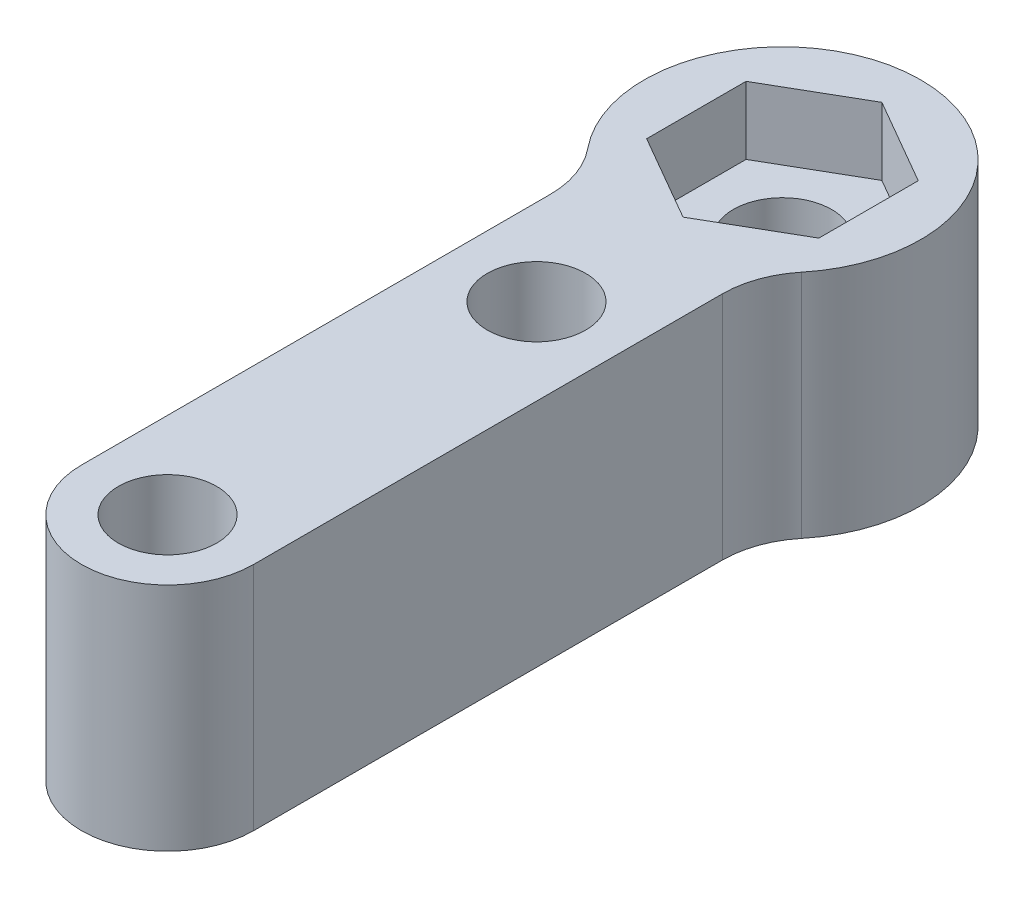
from build123d import *

# Parameters (mm, degrees)
SKETCH1_R           = 1.6
BOSS_EXTRUDE1_DEPTH = 7.5
CUT_EXTRUDE1_DEPTH  = 2.2
FILLET1_R           = 3


with BuildPart() as part:
    # Sketch1 → Boss-Extrude1 (new body)
    with BuildSketch(Plane(origin=(0, 0, 0), x_dir=(1, 0, 0), z_dir=(0, 1, 0))):
        with BuildLine():
            Line((-2.8, 0), (-2.8, 16.477217009))
            ThreePointArc((-2.8, 16.477217009), (0, 24.5), (2.8, 16.477217009))
            Line((2.8, 16.477217009), (2.8, 0))
            ThreePointArc((2.8, 0), (0, -2.8), (-2.8, 0))
        make_face()
        Circle(SKETCH1_R, mode=Mode.SUBTRACT)
        with Locations((0, 12)):
            Circle(SKETCH1_R, mode=Mode.SUBTRACT)
        with Locations((0, 20)):
            Circle(SKETCH1_R, mode=Mode.SUBTRACT)
    extrude(amount=BOSS_EXTRUDE1_DEPTH)

    # Sketch2 → Cut-Extrude1 (cut)
    with BuildSketch(Plane(origin=(0, 7.5, 0), x_dir=(1, 0, 0), z_dir=(0, 1, 0))):
        Polygon((0, 23.233161507), (-2.8, 21.616580754), (-2.8, 18.383419246), (0, 16.766838493), (2.8, 18.383419246), (2.8, 21.616580754), align=None)
    extrude(amount=-CUT_EXTRUDE1_DEPTH, mode=Mode.SUBTRACT)

    # Fillet1
    fillet1_edges = [part.edges().sort_by_distance(p)[0] for p in [
        (-2.8, 3.75, -16.477217009),
        (2.8, 3.75, -16.477217009),
    ]]
    fillet(fillet1_edges, radius=FILLET1_R)


solid = part.part
